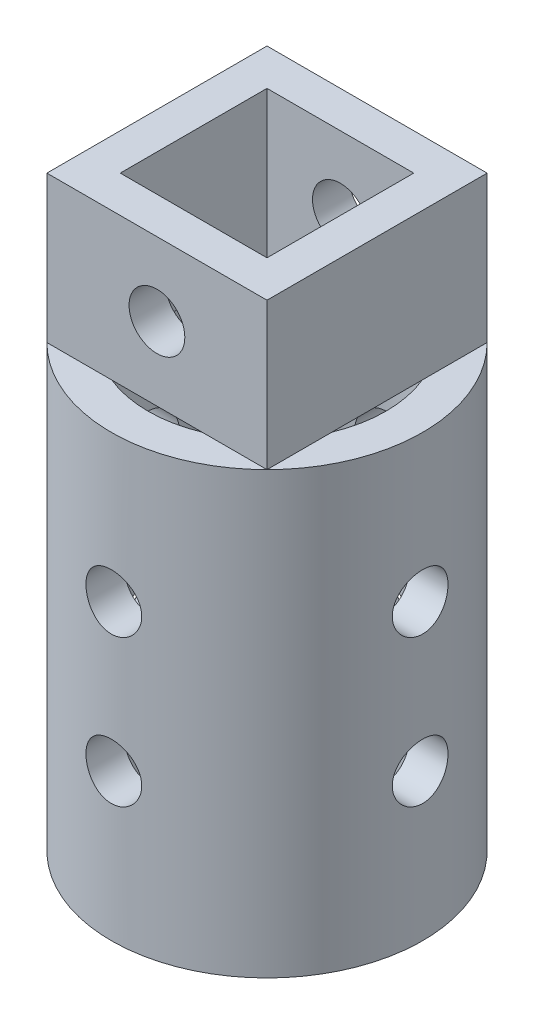
from build123d import *

# Parameters (mm, degrees)
SKETCH2_W               = 38.1
SKETCH2_H               = 38.1
SKETCH2_W_2             = 25.4
SKETCH2_H_2             = 25.4
BOSS_EXTRUDE1_DEPTH     = 25.4
SKETCH3_R               = 26.940768363
SKETCH3_R_2             = 20.590768363
BOSS_EXTRUDE2_DEPTH     = 76.2
SKETCH4_R               = 4.826
CUT_EXTRUDE1_DEPTH      = 50.8
SKETCH5_R               = 4.826
CUT_EXTRUDE2_DEPTH      = 27.940768363
CUT_EXTRUDE2_DEPTH_BACK = 27.940768363
SKETCH6_R               = 4.826
CUT_EXTRUDE3_DEPTH      = 27.940768463
CUT_EXTRUDE3_DEPTH_BACK = 27.940768463


with BuildPart() as part:
    # Sketch2 → Boss-Extrude1 (new body)
    with BuildSketch(Plane(origin=(0, 0, 0), x_dir=(1, 0, 0), z_dir=(0, 1, 0))):
        Rectangle(SKETCH2_W, SKETCH2_H)
        Rectangle(SKETCH2_W_2, SKETCH2_H_2, mode=Mode.SUBTRACT)
    extrude(amount=BOSS_EXTRUDE1_DEPTH)

    # Sketch3 → Boss-Extrude2 (add)
    with BuildSketch(Plane.XZ):
        Circle(SKETCH3_R)
        Circle(SKETCH3_R_2, mode=Mode.SUBTRACT)
    extrude(amount=BOSS_EXTRUDE2_DEPTH)

    # Sketch4 → Cut-Extrude1 (cut)
    with BuildSketch(Plane.XY.offset(19.05)):
        with Locations((0, 12.7)):
            Circle(SKETCH4_R)
    extrude(amount=-CUT_EXTRUDE1_DEPTH, mode=Mode.SUBTRACT)

    # Sketch5 → Cut-Extrude2 (cut, two sides)
    with BuildSketch(Plane.XY) as cut_extrude2_sk:
        with Locations((0, -25.4)):
            Circle(SKETCH5_R)
        with Locations((0, -50.8)):
            Circle(SKETCH5_R)
    extrude(amount=CUT_EXTRUDE2_DEPTH, mode=Mode.SUBTRACT)
    extrude(cut_extrude2_sk.sketch, amount=-CUT_EXTRUDE2_DEPTH_BACK, mode=Mode.SUBTRACT)

    # Sketch6 → Cut-Extrude3 (cut, two sides)
    with BuildSketch(Plane(origin=(0, 0, 0), x_dir=(0, 0, -1), z_dir=(1, 0, 0))) as cut_extrude3_sk:
        with Locations((0, -50.8)):
            Circle(SKETCH6_R)
        with Locations((0, -25.4)):
            Circle(SKETCH6_R)
    extrude(amount=CUT_EXTRUDE3_DEPTH, mode=Mode.SUBTRACT)
    extrude(cut_extrude3_sk.sketch, amount=-CUT_EXTRUDE3_DEPTH_BACK, mode=Mode.SUBTRACT)


solid = part.part
